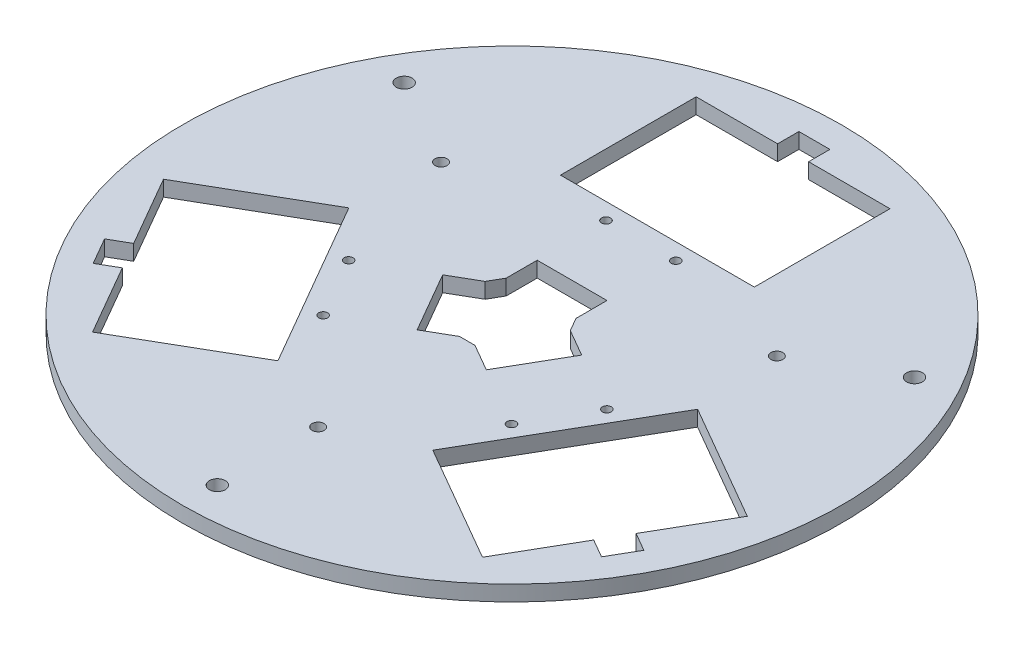
from build123d import *

# Parameters (mm, degrees)
SKETCH1_R           = 85
SKETCH1_R_2         = 2.05
SKETCH1_R_3         = 1.55
SKETCH1_W           = 50
SKETCH1_H           = 35
BOSS_EXTRUDE1_DEPTH = 2
SKETCH2_R           = 1.15
SKETCH2_R_2         = 1.150012437
CUT_EXTRUDE1_DEPTH  = 5
CUT_EXTRUDE2_START  = -4
CUT_EXTRUDE2_DEPTH  = 4
CUT_EXTRUDE3_REACH  = 6
SKETCH4_W           = 8
SKETCH4_H           = 5.5


with BuildPart() as part:
    # Sketch1 → Boss-Extrude1 (new body, symmetric)
    with BuildSketch(Plane(origin=(0, 0, 0), x_dir=(1, 0, 0), z_dir=(0, 1, 0))):
        Circle(SKETCH1_R)
        with Locations((65.817930688, 38)):
            Circle(SKETCH1_R_2, mode=Mode.SUBTRACT)
        with Locations((0, -76)):
            Circle(SKETCH1_R_2, mode=Mode.SUBTRACT)
        with Locations((-65.817930688, 38)):
            Circle(SKETCH1_R_2, mode=Mode.SUBTRACT)
        with Locations((43.301270189, 25)):
            Circle(SKETCH1_R_3, mode=Mode.SUBTRACT)
        with Locations((0, -50)):
            Circle(SKETCH1_R_3, mode=Mode.SUBTRACT)
        with Locations((-43.301270189, 25)):
            Circle(SKETCH1_R_3, mode=Mode.SUBTRACT)
        Polygon((75.286841774, -14.599364905), (50.286841774, -57.900635095), (19.975952642, -40.400635095), (44.975952642, 2.900635095), align=None, mode=Mode.SUBTRACT)
        with Locations((0, 55)):
            Rectangle(SKETCH1_W, SKETCH1_H, mode=Mode.SUBTRACT)
        Polygon((-50.286841774, -57.900635095), (-75.286841774, -14.599364905), (-44.975952642, 2.900635095), (-19.975952642, -40.400635095), align=None, mode=Mode.SUBTRACT)
        with BuildLine():
            Line((17.923393759, 0.044228634), (8.923393759, -15.544228634))
            Line((8.923393759, -15.544228634), (0.263139721, -10.544228634))
            Line((0.263139721, -10.544228634), (1.201188009, -8.91948134))
            ThreePointArc((1.201188009, -8.91948134), (0, -9), (-1.201188009, -8.91948134))
            Line((-1.201188009, -8.91948134), (-0.263139721, -10.544228634))
            Line((-0.263139721, -10.544228634), (-8.923393759, -15.544228634))
            Line((-8.923393759, -15.544228634), (-17.923393759, 0.044228634))
            Line((-17.923393759, 0.044228634), (-9.263139721, 5.044228634))
            Line((-9.263139721, 5.044228634), (-8.325091433, 3.41948134))
            ThreePointArc((-8.325091433, 3.41948134), (-7.794228634, 4.5), (-7.123903424, 5.5))
            Line((-7.123903424, 5.5), (-9, 5.5))
            Line((-9, 5.5), (-9, 15.5))
            Line((-9, 15.5), (9, 15.5))
            Line((9, 15.5), (9, 5.5))
            Line((9, 5.5), (7.123903424, 5.5))
            ThreePointArc((7.123903424, 5.5), (7.794228634, 4.5), (8.325091433, 3.41948134))
            Line((8.325091433, 3.41948134), (9.263139721, 5.044228634))
            Line((9.263139721, 5.044228634), (17.923393759, 0.044228634))
        make_face(mode=Mode.SUBTRACT)
    extrude(amount=BOSS_EXTRUDE1_DEPTH, both=True)

    # Sketch2 → Cut-Extrude1 (cut, through all)
    with BuildSketch(Plane(origin=(0, 2, 0), x_dir=(1, 0, 0), z_dir=(0, 1, 0))):
        with Locations((-9, 33.25)):
            Circle(SKETCH2_R)
        with Locations((9, 33.25)):
            Circle(SKETCH2_R)
        with Locations((-33.295344676, -8.830771366)):
            Circle(SKETCH2_R)
        with Locations((-24.295344676, -24.419228634)):
            Circle(SKETCH2_R)
        with Locations((24.295355446, -24.419234852)):
            Circle(SKETCH2_R_2)
        with Locations((33.295344676, -8.830771366)):
            Circle(SKETCH2_R)
    extrude(amount=-CUT_EXTRUDE1_DEPTH, mode=Mode.SUBTRACT)

    # Sketch3 → Cut-Extrude2 (cut)
    with BuildSketch(Plane(origin=(0, 2, 0), x_dir=(1, 0, 0), z_dir=(0, 1, 0)).offset(CUT_EXTRUDE2_START)):
        Polygon((9, 7.5), (-9, 7.5), (-10.995190528, 4.044228634), (-1.995190528, -11.544228634), (1.995190528, -11.544228634), (10.995190528, 4.044228634), align=None)
    extrude(amount=CUT_EXTRUDE2_DEPTH, mode=Mode.SUBTRACT)

    # Sketch4 → Cut-Extrude3 (cut, up to next)
    with BuildSketch(Plane(origin=(0, 2, 0), x_dir=(1, 0, 0), z_dir=(0, 1, 0)), mode=Mode.PRIVATE) as cut_extrude3_sk1:
        Polygon((64.786841774, -32.785898385), (69.549981495, -35.535898385), (65.549981495, -42.464101615), (60.786841774, -39.714101615), align=None)
    cut_extrude3_tool1 = extrude(cut_extrude3_sk1.sketch, amount=-CUT_EXTRUDE3_REACH, mode=Mode.PRIVATE) & part.part
    add(cut_extrude3_tool1.solids().sort_by_distance((65.168412, 2, 37.625))[0], mode=Mode.SUBTRACT)
    # Sketch4 → Cut-Extrude3 (cut, up to next)
    with BuildSketch(Plane(origin=(0, 2, 0), x_dir=(1, 0, 0), z_dir=(0, 1, 0)), mode=Mode.PRIVATE) as cut_extrude3_sk2:
        Polygon((-60.786841774, -39.714101615), (-64.786841774, -32.785898385), (-69.549981495, -35.535898385), (-65.549981495, -42.464101615), align=None)
    cut_extrude3_tool2 = extrude(cut_extrude3_sk2.sketch, amount=-CUT_EXTRUDE3_REACH, mode=Mode.PRIVATE) & part.part
    add(cut_extrude3_tool2.solids().sort_by_distance((-65.168412, 2, 37.625))[0], mode=Mode.SUBTRACT)
    # Sketch4 → Cut-Extrude3 (cut, up to next)
    with BuildSketch(Plane(origin=(0, 2, 0), x_dir=(1, 0, 0), z_dir=(0, 1, 0)), mode=Mode.PRIVATE) as cut_extrude3_sk3:
        with Locations((0, 75.25)):
            Rectangle(SKETCH4_W, SKETCH4_H)
    cut_extrude3_tool3 = extrude(cut_extrude3_sk3.sketch, amount=-CUT_EXTRUDE3_REACH, mode=Mode.PRIVATE) & part.part
    add(cut_extrude3_tool3.solids().sort_by_distance((0, 2, -75.25))[0], mode=Mode.SUBTRACT)


solid = part.part
